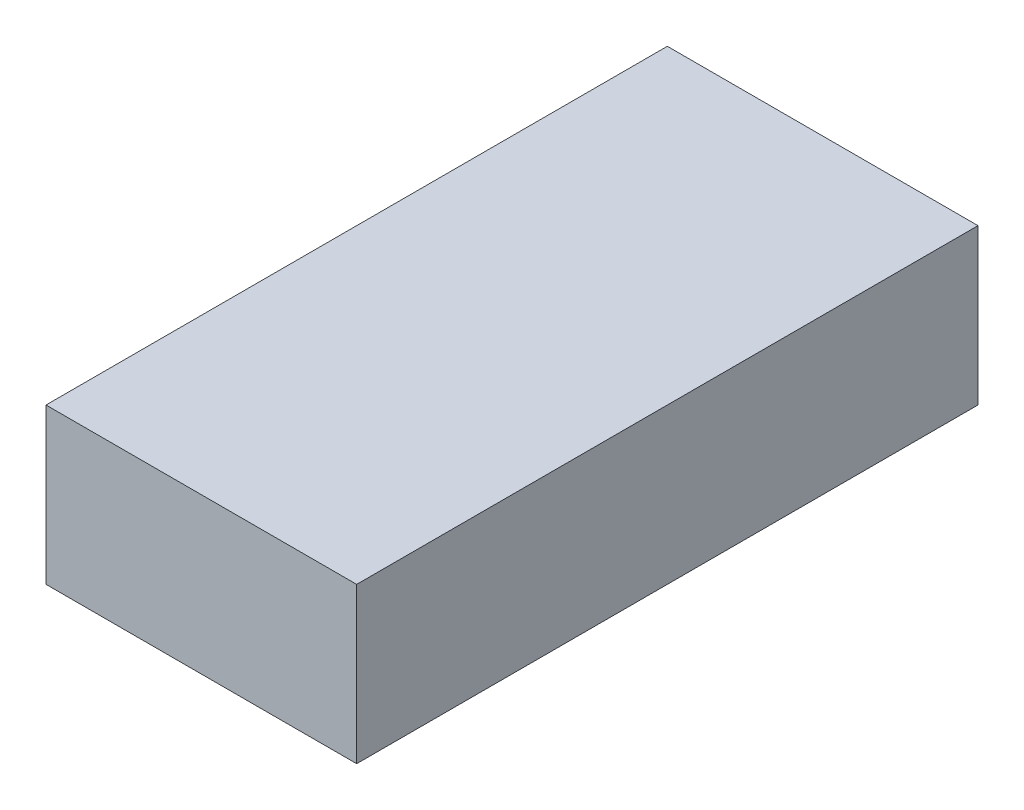
from build123d import *

# Parameters (mm, degrees)
SKETCH1_W           = 304.8
SKETCH1_H           = 609.6
BOSS_EXTRUDE1_DEPTH = 152.4


with BuildPart() as part:
    # Sketch1 → Boss-Extrude1 (new body)
    with BuildSketch(Plane(origin=(0, 0, 0), x_dir=(1, 0, 0), z_dir=(0, 1, 0))):
        with Locations((152.4, 304.8)):
            Rectangle(SKETCH1_W, SKETCH1_H)
    extrude(amount=BOSS_EXTRUDE1_DEPTH)


solid = part.part
